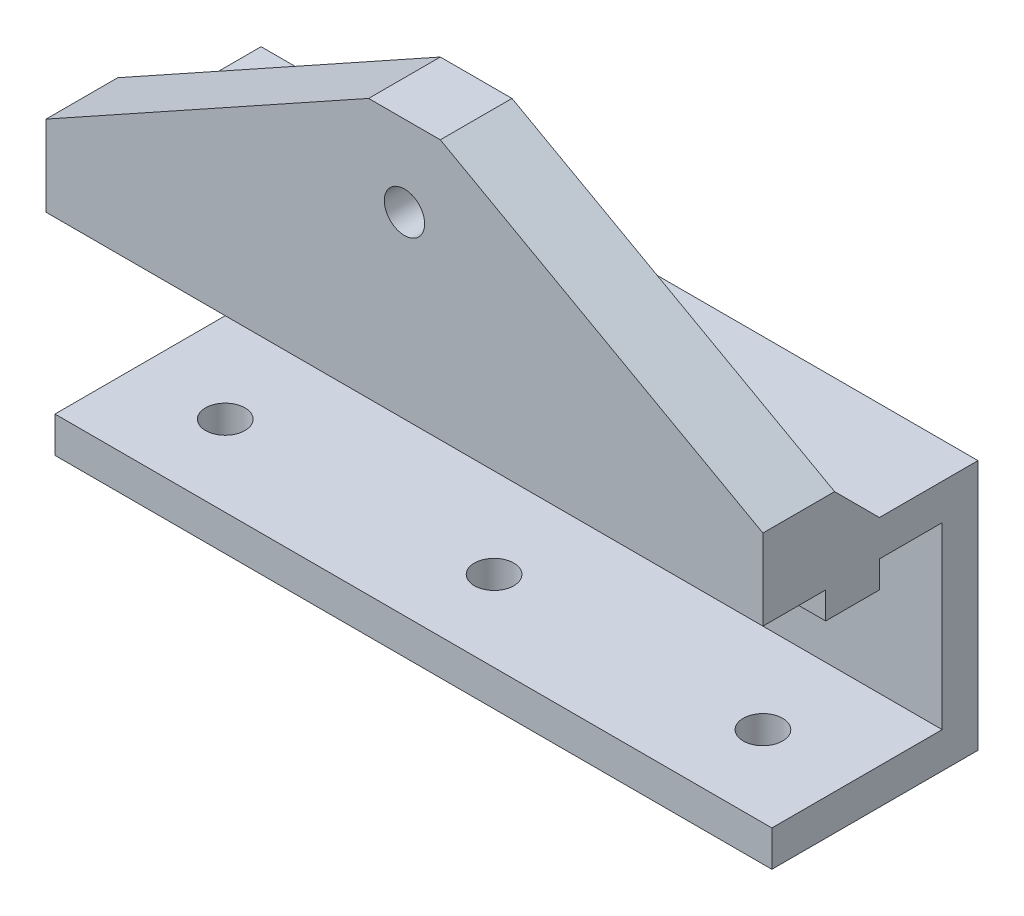
from build123d import *

# Parameters (mm, degrees)
BOSS_EXTRU_1_DEPTH      = 80
ENL_V_MAT_EXTRU_1_DEPTH = 9
D_GAGEMENT_M41_D        = 4.5
D_GAGEMENT_M41_DEPTH    = 10
D_GAGEMENT_M41_TIP      = 1.351936393
ENL_V_MAT_EXTRU_2_DEPTH = 4
D_GAGEMENT_M42_D        = 4.4
D_GAGEMENT_M42_DEPTH    = 10
D_GAGEMENT_M42_TIP      = 1.321893362


with BuildPart() as part:
    # Esquisse1 → Boss.-Extru.1 (new body)
    with BuildSketch(Plane(origin=(0, 0, 0), x_dir=(0, 0, -1), z_dir=(1, 0, 0))):
        Polygon((-33.838993879, -37.26557224), (-14.838993879, -37.26557224), (-14.838993879, -17.26557224), (-21.838993879, -17.26557224), (-21.838993879, -20.26557224), (-27.838993879, -20.26557224), (-27.838993879, -17.26557224), (-34.838993879, -17.26557224), (-34.838993879, 11.73442776), (-26.838993879, 11.73442776), (-26.838993879, -8.26557224), (-21.838993879, -13.26557224), (-10.838993879, -13.26557224), (-10.838993879, -41.26557224), (-33.838993879, -41.26557224), align=None)
    extrude(amount=BOSS_EXTRU_1_DEPTH)

    # Esquisse2 → Enlèv. mat.-Extru.1 (cut, through all)
    with BuildSketch(Plane(origin=(0, 0, 26.838993879), x_dir=(-1, 0, 0), z_dir=(0, 0, -1))):
        Polygon((-80, -8.26557224), (-44, 11.73442776), (-36, 11.73442776), (0, -8.26557224), (0, 11.73442776), (-36, 16.436885369), (-44, 16.436885369), (-80, 11.73442776), align=None)
    extrude(amount=-ENL_V_MAT_EXTRU_1_DEPTH, mode=Mode.SUBTRACT)

    # Dégagement M41
    with Locations(Plane(origin=(0, 0, 26.838993879), x_dir=(-1, 0, 0), z_dir=(0, 0, -1))):
        with Locations((-40, 2.73442776)):
            Hole(D_GAGEMENT_M41_D / 2, depth=D_GAGEMENT_M41_DEPTH)
            with Locations((0, 0, -(D_GAGEMENT_M41_DEPTH + D_GAGEMENT_M41_TIP / 2))):  # 118° drill point
                Cone(0, D_GAGEMENT_M41_D / 2, D_GAGEMENT_M41_TIP, mode=Mode.SUBTRACT)

    # Esquisse7 → Enlèv. mat.-Extru.2 (cut)
    with BuildSketch(Plane(origin=(0, 0, 26.838993879), x_dir=(-1, 0, 0), z_dir=(0, 0, -1))):
        Polygon((-40, 6.73442776), (-43.464101615, 4.73442776), (-43.464101615, 0.73442776), (-40, -1.26557224), (-36.535898385, 0.73442776), (-36.535898385, 4.73442776), align=None)
    extrude(amount=-ENL_V_MAT_EXTRU_2_DEPTH, mode=Mode.SUBTRACT)

    # Dégagement M42
    with Locations(Plane(origin=(0, -41.26557224, 0), x_dir=(-1, 0, 0), z_dir=(0, -1, 0))):
        with Locations((-10, -24.838993879), (-40, -24.838993879), (-70, -24.838993879)):
            Hole(D_GAGEMENT_M42_D / 2, depth=D_GAGEMENT_M42_DEPTH)
            with Locations((0, 0, -(D_GAGEMENT_M42_DEPTH + D_GAGEMENT_M42_TIP / 2))):  # 118° drill point
                Cone(0, D_GAGEMENT_M42_D / 2, D_GAGEMENT_M42_TIP, mode=Mode.SUBTRACT)


solid = part.part
